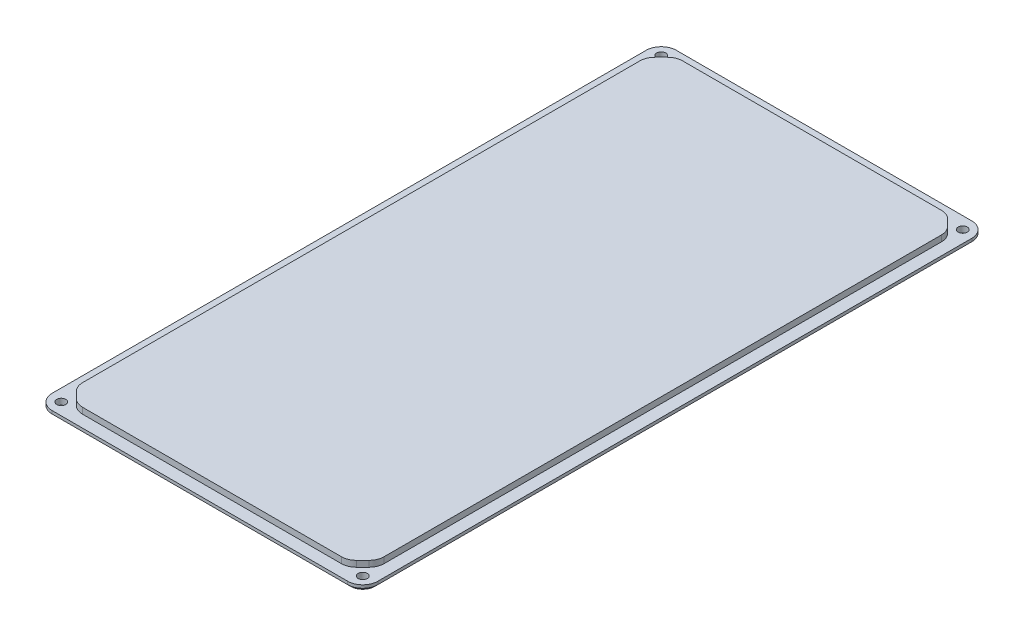
from build123d import *

# Parameters (mm, degrees)
SKETCH1_W                 = 108
SKETCH1_H                 = 207
BOSS_EXTRUDE1_DEPTH       = 2
SKETCH2_W                 = 100
SKETCH2_H                 = 199
BOSS_EXTRUDE2_DEPTH       = 2
CHAMFER1_SIZE             = 5
FILLET1_R                 = 5
F_3_0MM_DOWEL_HOLE1_D     = 3
F_3_0MM_DOWEL_HOLE1_DEPTH = 17.29
F_3_0MM_DOWEL_HOLE1_TIP   = 0.901290929
CHAMFER2_SIZE             = 1


with BuildPart() as part:
    # Sketch1 → Boss-Extrude1 (new body)
    with BuildSketch(Plane(origin=(0, 0, 0), x_dir=(1, 0, 0), z_dir=(0, 1, 0))):
        Rectangle(SKETCH1_W, SKETCH1_H)
    extrude(amount=BOSS_EXTRUDE1_DEPTH)

    # Sketch2 → Boss-Extrude2 (add)
    with BuildSketch(Plane(origin=(0, 2, 0), x_dir=(1, 0, 0), z_dir=(0, 1, 0))):
        Rectangle(SKETCH2_W, SKETCH2_H)
    extrude(amount=BOSS_EXTRUDE2_DEPTH)

    # Chamfer1
    chamfer1_edges = [part.edges().sort_by_distance(p)[0] for p in [
        (50, 3, 99.5),
        (50, 3, -99.5),
        (-50, 3, -99.5),
        (-50, 3, 99.5),
    ]]
    chamfer(chamfer1_edges, length=CHAMFER1_SIZE)

    # Fillet1
    fillet1_edges = [part.edges().sort_by_distance(p)[0] for p in [
        (-50, 3, 94.5),
        (-50, 3, -94.5),
        (45, 3, -99.5),
        (-45, 3, -99.5),
        (50, 3, 94.5),
        (50, 3, -94.5),
        (45, 3, 99.5),
        (-45, 3, 99.5),
        (54, 1, 103.5),
        (-54, 1, 103.5),
        (-54, 1, -103.5),
        (54, 1, -103.5),
    ]]
    fillet(fillet1_edges, radius=FILLET1_R)

    # Ø3.0mm Dowel Hole1
    with Locations(Plane(origin=(0, 0, 0), x_dir=(-1, 0, 0), z_dir=(0, -1, 0))):
        with Locations((-50, 99.5), (50, 99.5), (50, -99.5), (-50, -99.5)):
            Hole(F_3_0MM_DOWEL_HOLE1_D / 2, depth=F_3_0MM_DOWEL_HOLE1_DEPTH)
            with Locations((0, 0, -(F_3_0MM_DOWEL_HOLE1_DEPTH + F_3_0MM_DOWEL_HOLE1_TIP / 2))):  # 118° drill point
                Cone(0, F_3_0MM_DOWEL_HOLE1_D / 2, F_3_0MM_DOWEL_HOLE1_TIP, mode=Mode.SUBTRACT)

    # Chamfer2
    chamfer2_edges = [part.edges().sort_by_distance(p)[0] for p in [
        (0, 0, 103.5),
        (54, 0, 0),
        (-54, 0, 0),
        (0, 0, -103.5),
        (-52.535533906, 0, -102.035533906),
        (52.535533906, 0, -102.035533906),
        (52.535533906, 0, 102.035533906),
        (-52.535533906, 0, 102.035533906),
    ]]
    chamfer(chamfer2_edges, length=CHAMFER2_SIZE)


solid = part.part
